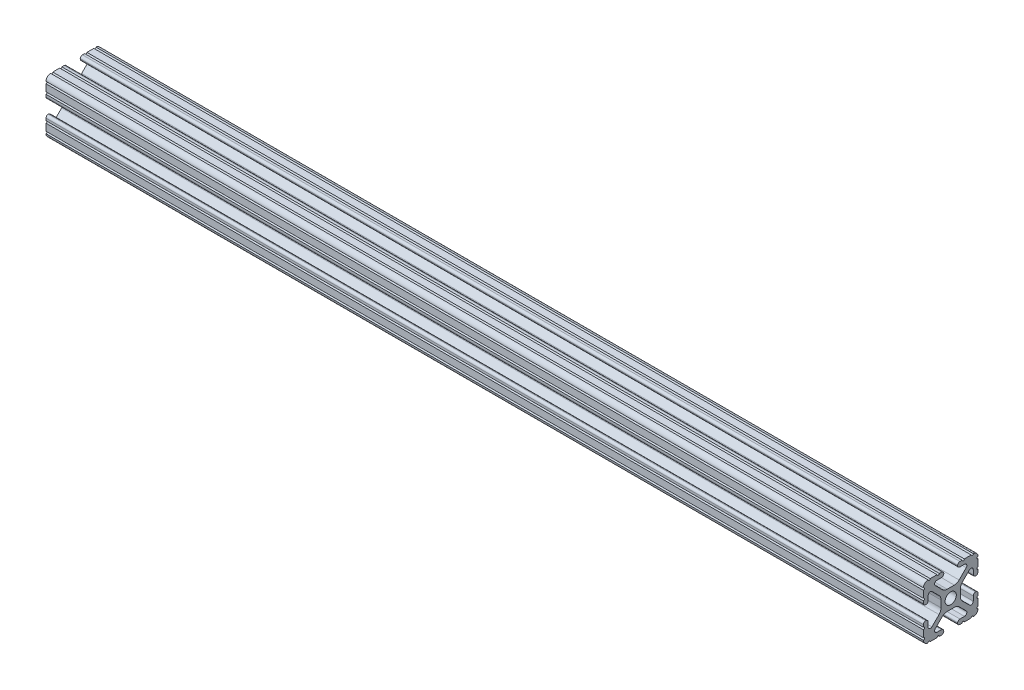
from build123d import *

# Parameters (mm, degrees)
SKETCH1_R                 = 2.6035
F_10_1010_PROFILE_1_DEPTH = 408.432
M6X1_0_TAPPED_HOLE1_D     = 5
M6X1_0_TAPPED_HOLE2_D     = 5


with BuildPart() as part:
    # Sketch1 → 10 1010 PROFILE(1) (new body)
    with BuildSketch(Plane.ZY):
        with BuildLine():
            Line((-1.709253557, -4.4958), (1.709253557, -4.4958))
            ThreePointArc((1.709253557, -4.4958), (2.922935876, -4.736928798), (3.95226937, -5.423689619))
            Line((3.95226937, -5.423689619), (7.179652728, -8.645192207))
            ThreePointArc((7.179652728, -8.645192207), (7.414733441, -9.822812921), (6.41641086, -10.4902))
            Line((6.41641086, -10.4902), (4.28752, -10.4902))
            ThreePointArc((4.28752, -10.4902), (3.545750844, -10.797450844), (3.2385, -11.53922))
            Line((3.2385, -11.53922), (3.2385, -11.65098))
            ThreePointArc((3.2385, -11.65098), (3.545750844, -12.392749156), (4.28752, -12.7))
            Line((4.28752, -12.7), (5.3171344, -12.7))
            ThreePointArc((5.3171344, -12.7), (5.8251344, -12.192), (6.3331344, -12.7))
            Line((6.3331344, -12.7), (9.5504, -12.7))
            ThreePointArc((9.5504, -12.7), (10.058323491, -12.192000006), (10.566399977, -12.699846982))
            ThreePointArc((10.566399977, -12.699846982), (12.082522516, -12.082522516), (12.699846982, -10.566399977))
            ThreePointArc((12.699846982, -10.566399977), (12.192000006, -10.058323491), (12.7, -9.5504))
            Line((12.7, -9.5504), (12.7, -6.3330836))
            ThreePointArc((12.7, -6.3330836), (12.192, -5.8250836), (12.7, -5.3170836))
            Line((12.7, -5.3170836), (12.7, -4.287470133))
            ThreePointArc((12.7, -4.287470133), (12.392749156, -3.545700977), (11.65098, -3.238450133))
            Line((11.65098, -3.238450133), (11.53922, -3.238450133))
            ThreePointArc((11.53922, -3.238450133), (10.797450844, -3.545700977), (10.4902, -4.287470133))
            Line((10.4902, -4.287470133), (10.4902, -6.402089023))
            ThreePointArc((10.4902, -6.402089023), (9.856394933, -7.351113629), (8.736962546, -7.129240479))
            Line((8.736962546, -7.129240479), (5.440484187, -3.838768792))
            ThreePointArc((5.440484187, -3.838768792), (4.75073678, -2.808015636), (4.5085, -1.591658411))
            Line((4.5085, -1.591658411), (4.5085, 1.591658411))
            ThreePointArc((4.5085, 1.591658411), (4.75073678, 2.808015636), (5.440484187, 3.838768792))
            Line((5.440484187, 3.838768792), (8.736962546, 7.129240479))
            ThreePointArc((8.736962546, 7.129240479), (9.856394933, 7.351113629), (10.4902, 6.402089023))
            Line((10.4902, 6.402089023), (10.4902, 4.287470133))
            ThreePointArc((10.4902, 4.287470133), (10.797450844, 3.545700977), (11.53922, 3.238450133))
            Line((11.53922, 3.238450133), (11.65098, 3.238450133))
            ThreePointArc((11.65098, 3.238450133), (12.392749156, 3.545700977), (12.7, 4.287470133))
            Line((12.7, 4.287470133), (12.7, 5.3171344))
            ThreePointArc((12.7, 5.3171344), (12.192, 5.8251344), (12.7, 6.3331344))
            Line((12.7, 6.3331344), (12.7, 9.5504))
            ThreePointArc((12.7, 9.5504), (12.192000006, 10.058323491), (12.699846982, 10.566399977))
            ThreePointArc((12.699846982, 10.566399977), (12.082522516, 12.082522516), (10.566399977, 12.699846982))
            ThreePointArc((10.566399977, 12.699846982), (10.058323491, 12.192000006), (9.5504, 12.7))
            Line((9.5504, 12.7), (6.3330836, 12.7))
            ThreePointArc((6.3330836, 12.7), (5.8250836, 12.192), (5.3170836, 12.7))
            Line((5.3170836, 12.7), (4.2874692, 12.7))
            ThreePointArc((4.2874692, 12.7), (3.545700044, 12.392749156), (3.2384492, 11.65098))
            Line((3.2384492, 11.65098), (3.2384492, 11.53922))
            ThreePointArc((3.2384492, 11.53922), (3.545700044, 10.797450844), (4.2874692, 10.4902))
            Line((4.2874692, 10.4902), (6.476774195, 10.4902))
            ThreePointArc((6.476774195, 10.4902), (7.43216212, 9.851515102), (7.207191475, 8.724540082))
            Line((7.207191475, 8.724540082), (3.900315394, 5.423689619))
            ThreePointArc((3.900315394, 5.423689619), (2.8709819, 4.736928798), (1.657299581, 4.4958))
            Line((1.657299581, 4.4958), (-1.657299581, 4.4958))
            ThreePointArc((-1.657299581, 4.4958), (-2.8709819, 4.736928798), (-3.900315394, 5.423689619))
            Line((-3.900315394, 5.423689619), (-7.207191475, 8.724540082))
            ThreePointArc((-7.207191475, 8.724540082), (-7.43216212, 9.851515102), (-6.476774195, 10.4902))
            Line((-6.476774195, 10.4902), (-4.2874692, 10.4902))
            ThreePointArc((-4.2874692, 10.4902), (-3.545700044, 10.797450844), (-3.2384492, 11.53922))
            Line((-3.2384492, 11.53922), (-3.2384492, 11.65098))
            ThreePointArc((-3.2384492, 11.65098), (-3.545700044, 12.392749156), (-4.2874692, 12.7))
            Line((-4.2874692, 12.7), (-5.3170836, 12.7))
            ThreePointArc((-5.3170836, 12.7), (-5.8250836, 12.192), (-6.3330836, 12.7))
            Line((-6.3330836, 12.7), (-9.5504, 12.7))
            ThreePointArc((-9.5504, 12.7), (-10.058323491, 12.192000006), (-10.566399977, 12.699846982))
            ThreePointArc((-10.566399977, 12.699846982), (-12.082522516, 12.082522516), (-12.699846982, 10.566399977))
            ThreePointArc((-12.699846982, 10.566399977), (-12.192000006, 10.058323491), (-12.7, 9.5504))
            Line((-12.7, 9.5504), (-12.7, 6.3331344))
            ThreePointArc((-12.7, 6.3331344), (-12.192, 5.8251344), (-12.7, 5.3171344))
            Line((-12.7, 5.3171344), (-12.7, 4.287470133))
            ThreePointArc((-12.7, 4.287470133), (-12.392749156, 3.545700977), (-11.65098, 3.238450133))
            Line((-11.65098, 3.238450133), (-11.53922, 3.238450133))
            ThreePointArc((-11.53922, 3.238450133), (-10.797450844, 3.545700977), (-10.4902, 4.287470133))
            Line((-10.4902, 4.287470133), (-10.4902, 6.402089023))
            ThreePointArc((-10.4902, 6.402089023), (-9.856394933, 7.351113629), (-8.736962546, 7.129240479))
            Line((-8.736962546, 7.129240479), (-5.440484187, 3.838768792))
            ThreePointArc((-5.440484187, 3.838768792), (-4.75073678, 2.808015636), (-4.5085, 1.591658411))
            Line((-4.5085, 1.591658411), (-4.5085, -1.591658411))
            ThreePointArc((-4.5085, -1.591658411), (-4.75073678, -2.808015636), (-5.440484187, -3.838768792))
            Line((-5.440484187, -3.838768792), (-8.736962546, -7.129240479))
            ThreePointArc((-8.736962546, -7.129240479), (-9.856394933, -7.351113629), (-10.4902, -6.402089023))
            Line((-10.4902, -6.402089023), (-10.4902, -4.287470133))
            ThreePointArc((-10.4902, -4.287470133), (-10.797450844, -3.545700977), (-11.53922, -3.238450133))
            Line((-11.53922, -3.238450133), (-11.65098, -3.238450133))
            ThreePointArc((-11.65098, -3.238450133), (-12.392749156, -3.545700977), (-12.7, -4.287470133))
            Line((-12.7, -4.287470133), (-12.7, -5.3170836))
            ThreePointArc((-12.7, -5.3170836), (-12.192, -5.8250836), (-12.7, -6.3330836))
            Line((-12.7, -6.3330836), (-12.7, -9.5504))
            ThreePointArc((-12.7, -9.5504), (-12.192000006, -10.058323491), (-12.699846982, -10.566399977))
            ThreePointArc((-12.699846982, -10.566399977), (-12.082522516, -12.082522516), (-10.566399977, -12.699846982))
            ThreePointArc((-10.566399977, -12.699846982), (-10.058323491, -12.192000006), (-9.5504, -12.7))
            Line((-9.5504, -12.7), (-6.3331344, -12.7))
            ThreePointArc((-6.3331344, -12.7), (-5.8251344, -12.192), (-5.3171344, -12.7))
            Line((-5.3171344, -12.7), (-4.28752, -12.7))
            ThreePointArc((-4.28752, -12.7), (-3.545750844, -12.392749156), (-3.2385, -11.65098))
            Line((-3.2385, -11.65098), (-3.2385, -11.53922))
            ThreePointArc((-3.2385, -11.53922), (-3.545750844, -10.797450844), (-4.28752, -10.4902))
            Line((-4.28752, -10.4902), (-6.41641086, -10.4902))
            ThreePointArc((-6.41641086, -10.4902), (-7.414733441, -9.822812921), (-7.179652728, -8.645192207))
            Line((-7.179652728, -8.645192207), (-3.95226937, -5.423689619))
            ThreePointArc((-3.95226937, -5.423689619), (-2.922935876, -4.736928798), (-1.709253557, -4.4958))
        make_face()
        Circle(SKETCH1_R, mode=Mode.SUBTRACT)
    extrude(amount=F_10_1010_PROFILE_1_DEPTH)

    # M6x1.0 Tapped Hole1 (through all)
    with Locations(Plane(origin=(-370.586, 12.7, 0), x_dir=(0, 0, 1), z_dir=(0, 1, 0))):
        with Locations((0, 0), (0, 310.388), (0, 286.512), (0, 156.464), (0, 129.794)):
            Hole(M6X1_0_TAPPED_HOLE1_D / 2)

    # M6x1.0 Tapped Hole2 (through all)
    with Locations(Plane(origin=(-33.274, 12.7, 0), x_dir=(0, 0, 1), z_dir=(0, 1, 0))):
        with Locations((0, 0)):
            Hole(M6X1_0_TAPPED_HOLE2_D / 2)


solid = part.part
